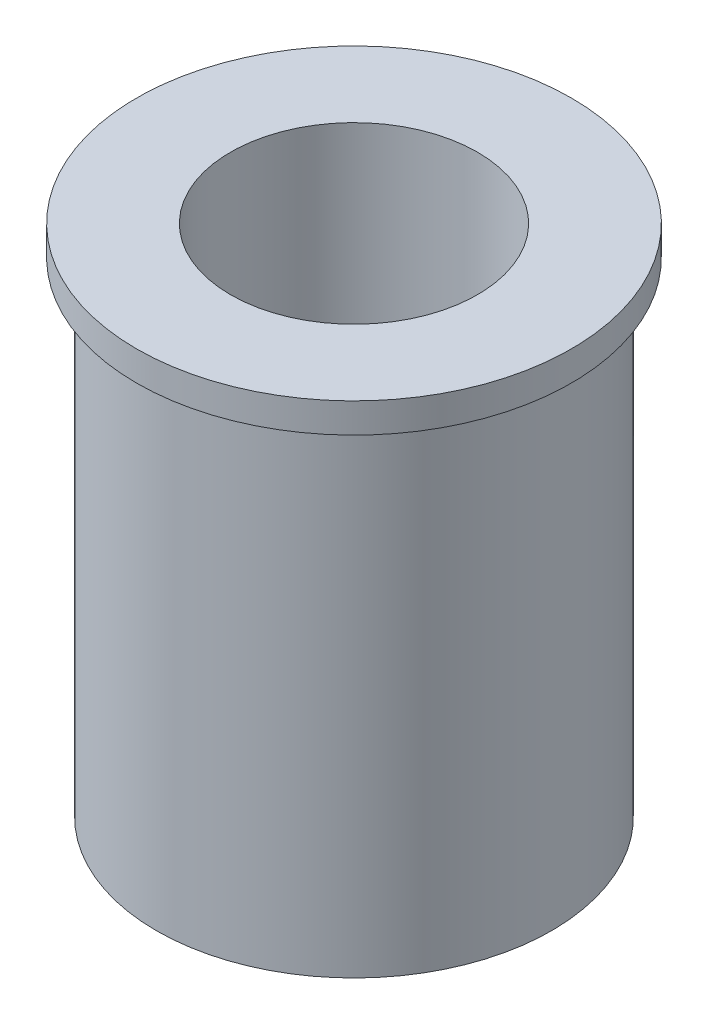
from build123d import *

# Parameters (mm, degrees)
SKIZZE1_R                       = 2
SKIZZE1_R_2                     = 1.25
AUFSATZ_LINEAR_AUSTRAGEN1_DEPTH = 4.9
SKIZZE2_R                       = 2.2
SKIZZE2_R_2                     = 1.25
AUFSATZ_LINEAR_AUSTRAGEN2_DEPTH = 0.3


with BuildPart() as part:
    # Skizze1 → Aufsatz-Linear austragen1 (new body)
    with BuildSketch(Plane(origin=(0, 0, 0), x_dir=(1, 0, 0), z_dir=(0, 1, 0))):
        Circle(SKIZZE1_R)
        Circle(SKIZZE1_R_2, mode=Mode.SUBTRACT)
    extrude(amount=AUFSATZ_LINEAR_AUSTRAGEN1_DEPTH)

    # Skizze2 → Aufsatz-Linear austragen2 (add)
    with BuildSketch(Plane(origin=(0, 4.9, 0), x_dir=(1, 0, 0), z_dir=(0, 1, 0))):
        Circle(SKIZZE2_R)
        Circle(SKIZZE2_R_2, mode=Mode.SUBTRACT)
    extrude(amount=AUFSATZ_LINEAR_AUSTRAGEN2_DEPTH)


solid = part.part
